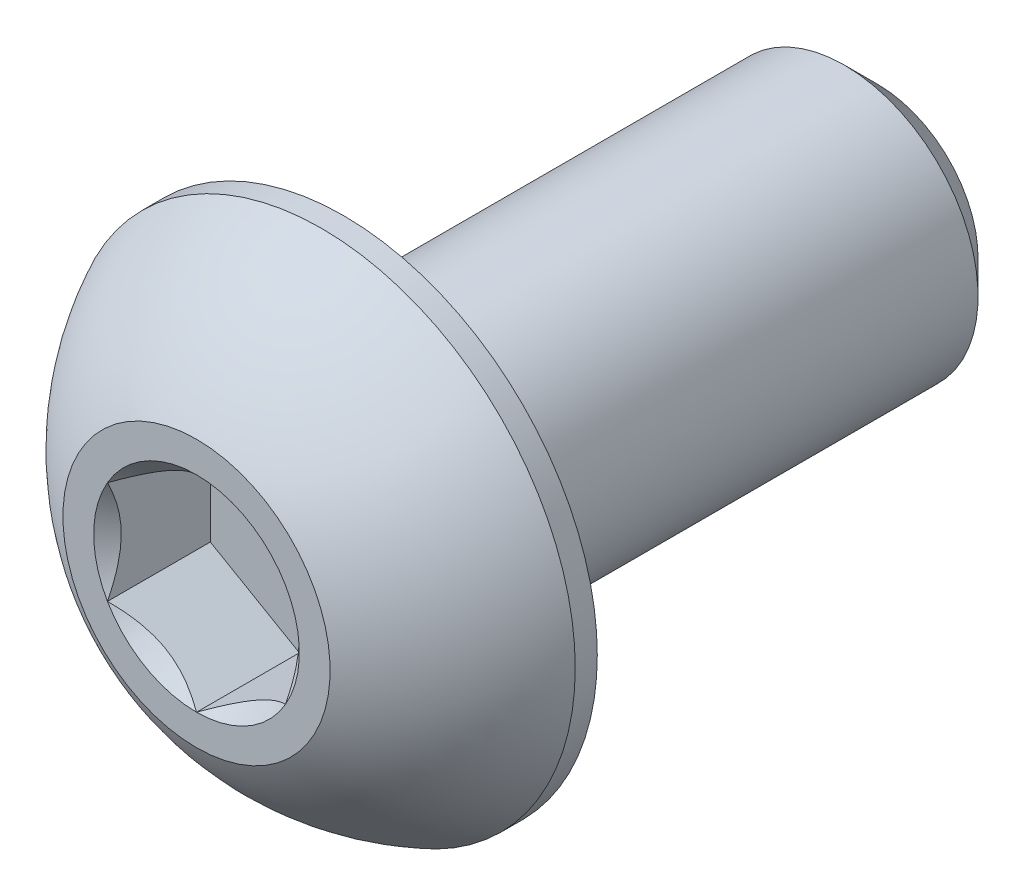
from build123d import *

# Parameters (mm, degrees)
SKETCH1_W          = 6
SKETCH1_H          = 1.5
CHAMFER1_SIZE      = 0.375
CUT_EXTRUDE2_DEPTH = 1.155


with BuildPart() as part:
    # Sketch1 → Revolve1 (revolve)
    with BuildSketch(Plane(origin=(0, 0, 0), x_dir=(0, 0, -1), z_dir=(1, 0, 0))):
        with Locations((4.65, 0.75)):
            Rectangle(SKETCH1_W, SKETCH1_H)
    revolve(axis=Axis((0, 0, -7.65), (0, 0, 1)))

    # Chamfer1
    chamfer1_edges = [part.edges().sort_by_distance(p)[0] for p in [
        (0, -1.5, -7.65),
    ]]
    chamfer(chamfer1_edges, length=CHAMFER1_SIZE)

    # Sketch7 → Revolve2 (revolve)
    with BuildSketch(Plane(origin=(0, 0, 0), x_dir=(0, 0, -1), z_dir=(1, 0, 0))):
        with BuildLine():
            Line((1.4025, 2.85), (1.65, 2.85))
            Line((1.65, 2.85), (1.65, 0))
            Line((1.65, 0), (0, 0))
            Line((0, 0), (0, 1.5))
            ThreePointArc((0, 1.5), (0.59512511, 2.285251969), (1.4025, 2.85))
        make_face()
    revolve(axis=Axis((0, 0, 0), (0, 0, -1)))

    # Sketch5 → Cut-Extrude2 (cut)
    with BuildSketch(Plane.XY):
        Polygon((1, -0.577350269), (1, 0.577350269), (0, 1.154700538), (-1, 0.577350269), (-1, -0.577350269), (0, -1.154700538), align=None)
    extrude(amount=-CUT_EXTRUDE2_DEPTH, mode=Mode.SUBTRACT)

    # Cut-Extrude3 cone 1 section (through the dimple's axis) → Cut-Extrude3 (revolve, cut)
    with BuildSketch(Plane(origin=(0, 0, 0), x_dir=(0, -1, 0), z_dir=(1, 0, 0))):
        Polygon((0, 0), (1.154700538, 0), (0, 1.154700538), align=None)
    revolve(axis=Axis((0, 0, 0), (0, 0, -1)), mode=Mode.SUBTRACT)


solid = part.part
